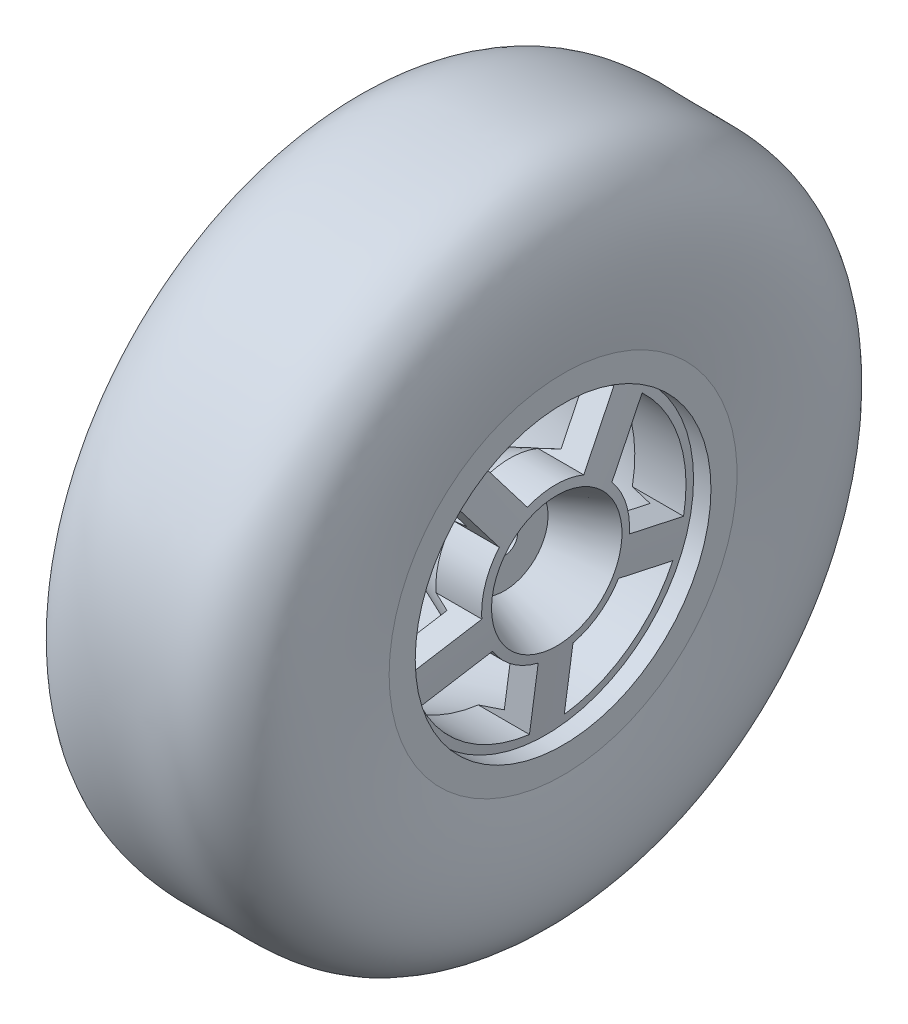
from build123d import *

# Parameters (mm, degrees)
CUT_EXTRUDE1_REACH = 21.23
SKETCH3_R          = 1.5
CUT_EXTRUDE2_DEPTH = 26.95888467
CUT_EXTRUDE3_DEPTH = 10


with BuildPart() as part:
    # Sketch2 → Revolve1 (revolve)
    with BuildSketch(Plane.XY):
        with BuildLine():
            Line((0, 4.5), (11.721248341, 9.383853475))
            Line((11.721248341, 9.383853475), (10.96991248, 15))
            Line((10.96991248, 15), (-10, 22))
            Line((-10, 22), (-10, 23))
            Line((-10, 23), (-9.5, 23))
            add(Edge.make_bspline(
                [(-9.5, 23), (-9.184580705, 24.805210342), (-11.680572374, 29.481442907), (-6.228226752, 39.190854706), (6.249334684, 37.877953806), (13.043419089, 39.508483339), (17.603844738, 30.624473337), (15.729076842, 20)],
                knots=[0, 0, 0, 0, 0.229957765, 0.280779104, 0.508213391, 0.824609493, 1, 1, 1, 1], degree=3))
            Line((15.729076842, 20), (15.729076842, 17))
            Line((15.729076842, 17), (13.729076842, 17))
            Line((13.729076842, 17), (15, 7.5))
            Line((15, 7.5), (9, 5))
            Line((9, 5), (9, 0))
            Line((9, 0), (-1.5, 0))
            Line((-1.5, 0), (-1.5, 4.5))
            Line((-1.5, 4.5), (0, 4.5))
        make_face()
    revolve(axis=Axis((-63.183775164, 0, 0), (1, 0, 0)))

    # Sketch3 → Cut-Extrude1 (cut, up to next)
    with BuildSketch(Plane(origin=(9, 0, 0), x_dir=(0, 0, -1), z_dir=(1, 0, 0)), mode=Mode.PRIVATE) as cut_extrude1_sk1:
        Circle(SKETCH3_R)
    cut_extrude1_tool1 = extrude(cut_extrude1_sk1.sketch, amount=-CUT_EXTRUDE1_REACH, mode=Mode.PRIVATE) & part.part
    add(cut_extrude1_tool1.solids().sort_by_distance((9, 0, 0))[0], mode=Mode.SUBTRACT)

    # Sketch4 → Cut-Extrude2 (cut, through all)
    with BuildSketch(Plane(origin=(15.729076842, 0, 0), x_dir=(0, 0, -1), z_dir=(1, 0, 0))):
        with BuildLine():
            Line((-6.932428082, 12.94427191), (6.932428082, 12.94427191))
            Line((6.932428082, 12.94427191), (7.712767623, 14.018317146))
            ThreePointArc((7.712767623, 14.018317146), (0, 16), (-7.712767623, 14.018317146))
            Line((-7.712767623, 14.018317146), (-6.932428082, 12.94427191))
        make_face()
        with BuildLine():
            Line((-6.932428082, 12.94427191), (-3.237869127, 7.85914776))
            ThreePointArc((-3.237869127, 7.85914776), (0, 8.5), (3.237869127, 7.85914776))
            Line((3.237869127, 7.85914776), (6.932428082, 12.94427191))
            Line((6.932428082, 12.94427191), (-6.932428082, 12.94427191))
        make_face()
        with BuildLine():
            Line((10.168496059, 10.593130901), (14.452972238, -2.593130901))
            Line((14.452972238, -2.593130901), (15.715588138, -3.003379675))
            ThreePointArc((15.715588138, -3.003379675), (15.92873834, -1.508408067), (16, 0))
            ThreePointArc((16, 0), (14.683006668, 6.356832167), (10.9488356, 11.667176137))
            Line((10.9488356, 11.667176137), (10.168496059, 10.593130901))
        make_face()
        with BuildLine():
            Line((8.475050276, -0.650786313), (14.452972238, -2.593130901))
            Line((14.452972238, -2.593130901), (10.168496059, 10.593130901))
            Line((10.168496059, 10.593130901), (6.473937104, 5.508006751))
            ThreePointArc((6.473937104, 5.508006751), (7.977420178, 2.934410896), (8.5, 0))
            ThreePointArc((8.5, 0), (8.493760279, -0.325632198), (8.475050276, -0.650786313))
        make_face()
        with BuildLine():
            Line((13.216904261, -6.397356966), (2, -14.546914944))
            Line((2, -14.546914944), (2, -15.874507866))
            ThreePointArc((2, -15.874507866), (9.404564037, -12.94427191), (14.479520161, -6.807605741))
            Line((14.479520161, -6.807605741), (13.216904261, -6.397356966))
        make_face()
        with BuildLine():
            Line((2, -8.261355821), (2, -14.546914944))
            Line((2, -14.546914944), (13.216904261, -6.397356966))
            Line((13.216904261, -6.397356966), (7.238982298, -4.455012378))
            ThreePointArc((7.238982298, -4.455012378), (4.996174644, -6.876644452), (2, -8.261355821))
        make_face()
        with BuildLine():
            Line((-2, -15.874507866), (-2, -14.546914944))
            Line((-2, -14.546914944), (-13.216904261, -6.397356966))
            Line((-13.216904261, -6.397356966), (-14.479520161, -6.807605741))
            ThreePointArc((-14.479520161, -6.807605741), (-9.404564037, -12.94427191), (-2, -15.874507866))
        make_face()
        with BuildLine():
            Line((-13.216904261, -6.397356966), (-2, -14.546914944))
            Line((-2, -14.546914944), (-2, -8.261355821))
            ThreePointArc((-2, -8.261355821), (-4.996174644, -6.876644452), (-7.238982298, -4.455012378))
            Line((-7.238982298, -4.455012378), (-13.216904261, -6.397356966))
        make_face()
        with BuildLine():
            Line((-15.715588138, -3.003379675), (-14.452972238, -2.593130901))
            Line((-14.452972238, -2.593130901), (-10.168496059, 10.593130901))
            Line((-10.168496059, 10.593130901), (-10.9488356, 11.667176137))
            ThreePointArc((-10.9488356, 11.667176137), (-15.216904261, 4.94427191), (-15.715588138, -3.003379675))
        make_face()
        with BuildLine():
            Line((-10.168496059, 10.593130901), (-14.452972238, -2.593130901))
            Line((-14.452972238, -2.593130901), (-8.475050276, -0.650786313))
            ThreePointArc((-8.475050276, -0.650786313), (-8.083980389, 2.626644452), (-6.473937104, 5.508006751))
            Line((-6.473937104, 5.508006751), (-10.168496059, 10.593130901))
        make_face()
    extrude(amount=-CUT_EXTRUDE2_DEPTH, mode=Mode.SUBTRACT)

    # Sketch5 → Cut-Extrude3 (cut)
    with BuildSketch(Plane.ZY.offset(1.5)):
        Polygon((0, -2.886751346), (2.5, -1.443375673), (2.5, 1.443375673), (0, 2.886751346), (-2.5, 1.443375673), (-2.5, -1.443375673), align=None)
    extrude(amount=-CUT_EXTRUDE3_DEPTH, mode=Mode.SUBTRACT)


solid = part.part
